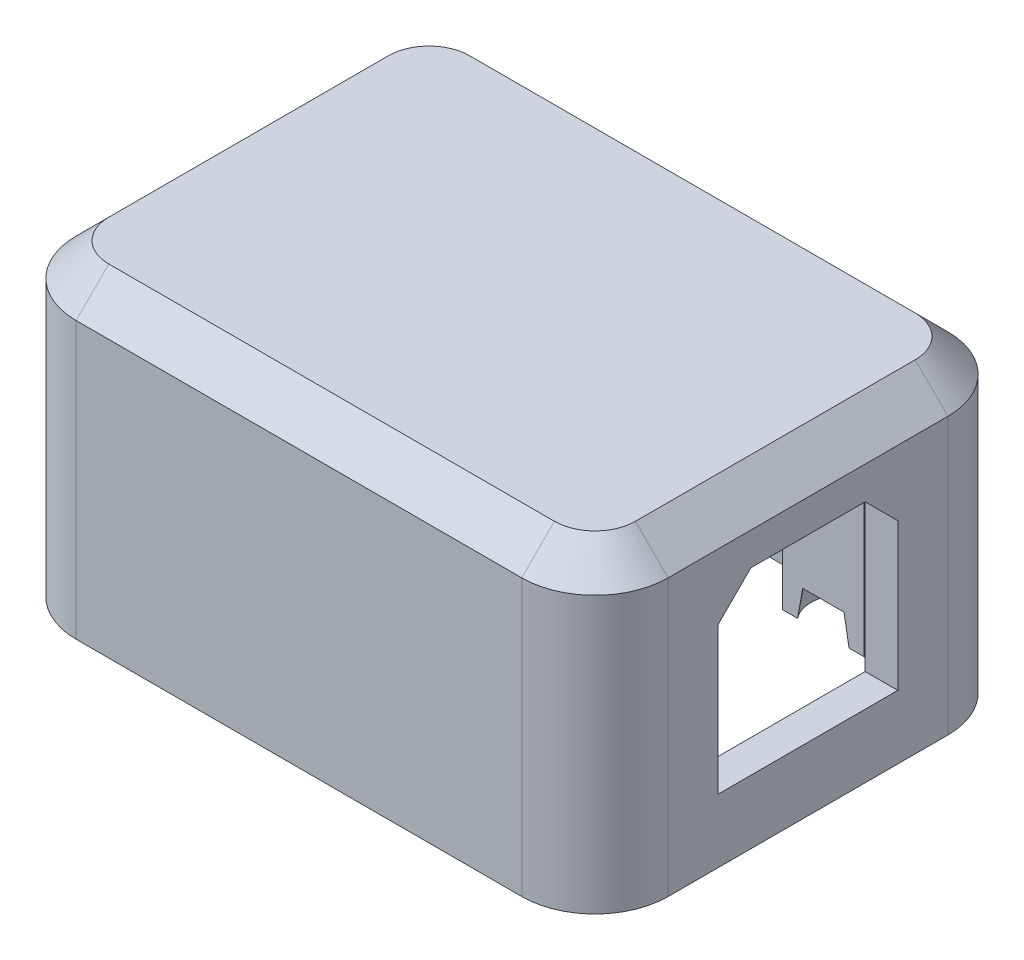
from build123d import *

# Parameters (mm, degrees)
MAIN_EXTRUSION_DEPTH             = 14
TAPERED_BOTTOM_DEPTH             = 2
TAPERED_BOTTOM_DRAFT             = -45
SKETCH4_R                        = 2.795
SKETCH4_W                        = 8
SKETCH4_H                        = 3.045
PCB_SUPPORT_DEPTH                = 13.75
SKETCH5_R                        = 2.045
GUIDE_PIN_CUTOUT_DEPTH           = 2
GUIDE_PIN_CUTOUT_DRAFT           = 7.5
GUIDE_PIN_CUTOUT_PROFILE_2_DEPTH = 2
GUIDE_PIN_CUTOUT_PROFILE_2_DRAFT = 7.5
SKETCH12_W                       = 4.994797294
SKETCH12_H                       = 14
CUT_EXTRUDE6_DEPTH               = 13.75
SKETCH11_W                       = 7
SKETCH11_H                       = 7
BOSS_EXTRUDE1_DEPTH              = 2
CUT_EXTRUDE2_REACH               = 48.243
SKETCH8_R                        = 6.5
CUT_EXTRUDE4_DEPTH               = 0.5
CUT_EXTRUDE5_REACH               = 48.243
CHAMFER1_SIZE                    = 0.5


with BuildPart() as part:
    # Sketch2 → main-extrusion (new body)
    with BuildSketch(Plane(origin=(0, 0, 0), x_dir=(1, 0, 0), z_dir=(0, 1, 0))):
        with BuildLine():
            Line((-2.25, 19.36), (-2.25, 2.23))
            ThreePointArc((-2.25, 2.23), (-0.93783838, -0.93783838), (2.23, -2.25))
            Line((2.23, -2.25), (29.52, -2.25))
            ThreePointArc((29.52, -2.25), (32.68783838, -0.93783838), (34, 2.23))
            Line((34, 2.23), (34, 19.36))
            ThreePointArc((34, 19.36), (32.68783838, 22.52783838), (29.52, 23.84))
            Line((29.52, 23.84), (2.23, 23.84))
            ThreePointArc((2.23, 23.84), (-0.93783838, 22.52783838), (-2.25, 19.36))
        make_face()
        with BuildLine():
            Line((-0.25, 19.36), (-0.25, 2.23))
            ThreePointArc((-0.25, 2.23), (0.476375183, 0.476375183), (2.23, -0.25))
            Line((2.23, -0.25), (29.52, -0.25))
            ThreePointArc((29.52, -0.25), (31.273624817, 0.476375183), (32, 2.23))
            Line((32, 2.23), (32, 19.36))
            ThreePointArc((32, 19.36), (31.273624817, 21.113624817), (29.52, 21.84))
            Line((29.52, 21.84), (2.23, 21.84))
            ThreePointArc((2.23, 21.84), (0.476375183, 21.113624817), (-0.25, 19.36))
        make_face(mode=Mode.SUBTRACT)
    extrude(amount=MAIN_EXTRUSION_DEPTH)


with BuildPart() as tapered_bottom_tool:
    # Sketch3 → tapered-bottom (with draft: the straight prism first)
    with BuildSketch(Plane.XZ.offset(-14)):
        with BuildLine():
            ThreePointArc((-2.25, -19.36), (-0.93783838, -22.52783838), (2.23, -23.84))
            Line((2.23, -23.84), (29.52, -23.84))
            ThreePointArc((29.52, -23.84), (32.68783838, -22.52783838), (34, -19.36))
            Line((34, -19.36), (34, -2.23))
            ThreePointArc((34, -2.23), (32.68783838, 0.93783838), (29.52, 2.25))
            Line((29.52, 2.25), (2.23, 2.25))
            ThreePointArc((2.23, 2.25), (-0.93783838, 0.93783838), (-2.25, -2.23))
            Line((-2.25, -2.23), (-2.25, -19.36))
        make_face()
    extrude(amount=-TAPERED_BOTTOM_DEPTH)
    # tapered-bottom: the draft: its side faces are tilted about the plane it starts from
    tapered_bottom_sides = [tapered_bottom_tool.faces().sort_by_distance(p)[0] for p in [
        (-0.93783838, 15, -22.52783838),
        (15.875, 15, -23.84),
        (32.68783838, 15, -22.52783838),
        (34, 15, -10.795),
        (32.68783838, 15, 0.93783838),
        (15.875, 15, 2.25),
        (-0.93783838, 15, 0.93783838),
        (-2.25, 15, -10.795),
    ]]
    draft(tapered_bottom_sides, Plane.XZ.offset(-14), TAPERED_BOTTOM_DRAFT)


with BuildPart() as part_1:
    add(part.part)

    # tapered-bottom: add tapered_bottom_tool
    add(tapered_bottom_tool.part)

    # Sketch4 → PCB-support (add)
    with BuildSketch(Plane(origin=(0, 14, 0), x_dir=(1, 0, 0), z_dir=(0, 1, 0))):
        with Locations((27.94, 19.05)):
            Circle(SKETCH4_R)
        with Locations((27.94, 2.54)):
            Circle(SKETCH4_R)
        with Locations((13, 20.3175)):
            Rectangle(SKETCH4_W, SKETCH4_H)
        with Locations((13, 1.2725)):
            Rectangle(SKETCH4_W, SKETCH4_H)
    extrude(amount=-PCB_SUPPORT_DEPTH)


with BuildPart() as guide_pin_cutout_tool:
    # Sketch5 → guide-pin-cutout (with draft: the straight prism first)
    with BuildSketch(Plane(origin=(0, 0, 0), x_dir=(1, 0, 0), z_dir=(0, 1, 0))):
        with Locations((27.94, 19.05)):
            Circle(SKETCH5_R)
    extrude(amount=GUIDE_PIN_CUTOUT_DEPTH)
    # guide-pin-cutout: the draft: its side faces are tilted about the plane it starts from
    guide_pin_cutout_sides = [guide_pin_cutout_tool.faces().sort_by_distance(p)[0] for p in [
        (25.895, 1, -19.05),
    ]]
    draft(guide_pin_cutout_sides, Plane(origin=(0, 0, 0), x_dir=(1, 0, 0), z_dir=(0, 1, 0)), GUIDE_PIN_CUTOUT_DRAFT)


with BuildPart() as part_2:
    add(part_1.part)

    # guide-pin-cutout: cut by guide_pin_cutout_tool
    add(guide_pin_cutout_tool.part, mode=Mode.SUBTRACT)


with BuildPart() as guide_pin_cutout_profile_2_tool:
    # Sketch5 → guide-pin-cutout profile 2 (with draft: the straight prism first)
    with BuildSketch(Plane(origin=(0, 0, 0), x_dir=(1, 0, 0), z_dir=(0, 1, 0))):
        with Locations((27.94, 2.54)):
            Circle(SKETCH5_R)
    extrude(amount=GUIDE_PIN_CUTOUT_PROFILE_2_DEPTH)
    # guide-pin-cutout profile 2: the draft: its side faces are tilted about the plane it starts from
    guide_pin_cutout_profile_2_sides = [guide_pin_cutout_profile_2_tool.faces().sort_by_distance(p)[0] for p in [
        (25.895, 1, -2.54),
    ]]
    draft(guide_pin_cutout_profile_2_sides, Plane(origin=(0, 0, 0), x_dir=(1, 0, 0), z_dir=(0, 1, 0)), GUIDE_PIN_CUTOUT_PROFILE_2_DRAFT)


with BuildPart() as part_3:
    add(part_2.part)

    # guide-pin-cutout profile 2: cut by guide_pin_cutout_profile_2_tool
    add(guide_pin_cutout_profile_2_tool.part, mode=Mode.SUBTRACT)

    # Sketch12 → Cut-Extrude6 (cut)
    with BuildSketch(Plane.XZ.offset(-14)):
        with Locations((27.94, -10.795)):
            Rectangle(SKETCH12_W, SKETCH12_H)
    extrude(amount=CUT_EXTRUDE6_DEPTH, mode=Mode.SUBTRACT)

    # Sketch11 → Boss-Extrude1 (add)
    with BuildSketch(Plane.XZ.offset(-14)):
        with Locations((28.5, -10.795)):
            Rectangle(SKETCH11_W, SKETCH11_H)
    extrude(amount=BOSS_EXTRUDE1_DEPTH)

    # top-hook: sweep along a path in path
    with BuildLine(Plane.XZ) as top_hook_path:
        Line((2.23, 0.25), (29.52, 0.25))
        ThreePointArc((29.52, 0.25), (31.273624817, -0.476375183), (32, -2.23))
        Line((32, -2.23), (32, -19.36))
        ThreePointArc((32, -19.36), (31.273624817, -21.113624817), (29.52, -21.84))
        Line((29.52, -21.84), (2.23, -21.84))
        ThreePointArc((2.23, -21.84), (0.476375183, -21.113624817), (-0.25, -19.36))
        Line((-0.25, -19.36), (-0.25, -2.23))
        ThreePointArc((-0.25, -2.23), (0.476375183, -0.476375183), (2.23, 0.25))
    # hook → top-hook (sweep)
    with BuildSketch(Plane(origin=(29.52, 0, 0), x_dir=(0, 0, -1), z_dir=(1, 0, 0))):
        with BuildLine():
            Line((22.84, -2.9), (22.84, -1.3))
            ThreePointArc((22.84, -1.3), (23.19, -0.75), (22.84, -0.2))
            Line((22.84, -0.2), (22.84, 0))
            Line((22.84, 0), (23.84, 0))
            Line((23.84, 0), (23.84, -2.9))
            Line((23.84, -2.9), (22.84, -2.9))
        make_face()
    sweep(path=top_hook_path.line)

    # Sketch8 → Cut-Extrude2 (cut, up to next)
    with BuildSketch(Plane.ZY.offset(2.25), mode=Mode.PRIVATE) as cut_extrude2_sk1:
        with Locations((-10.795, 7)):
            Circle(SKETCH8_R)
    cut_extrude2_tool1 = extrude(cut_extrude2_sk1.sketch, amount=-CUT_EXTRUDE2_REACH, mode=Mode.PRIVATE) & part_3.part
    add(cut_extrude2_tool1.solids().sort_by_distance((-2.25, 7, -10.795))[0], mode=Mode.SUBTRACT)

    # Sketch9 → Cut-Extrude4 (cut)
    with BuildSketch(Plane.ZY.offset(2.25)):
        with BuildLine():
            Line((-18.295, 7), (-18.295, 12))
            ThreePointArc((-18.295, 12), (-17.709213562, 13.414213562), (-16.295, 14))
            Line((-16.295, 14), (-5.295, 14))
            ThreePointArc((-5.295, 14), (-3.880786438, 13.414213562), (-3.295, 12))
            Line((-3.295, 12), (-3.295, 7))
            ThreePointArc((-3.295, 7), (-10.795, -0.5), (-18.295, 7))
        make_face()
    extrude(amount=-CUT_EXTRUDE4_DEPTH, mode=Mode.SUBTRACT)

    # Sketch10 → Cut-Extrude5 (cut, up to next)
    with BuildSketch(Plane(origin=(34, 0, 0), x_dir=(0, 0, -1), z_dir=(1, 0, 0)), mode=Mode.PRIVATE) as cut_extrude5_sk1:
        Polygon((5.295, 1), (16.295, 1), (16.295, 10), (14.295, 12), (7.295, 12), (5.295, 10), align=None)
    cut_extrude5_tool1 = extrude(cut_extrude5_sk1.sketch, amount=-CUT_EXTRUDE5_REACH, mode=Mode.PRIVATE) & part_3.part
    add(cut_extrude5_tool1.solids().sort_by_distance((34, 6.334758, -10.795))[0], mode=Mode.SUBTRACT)

    # Chamfer1
    chamfer1_edges = [part_3.edges().sort_by_distance(p)[0] for p in [
        (15.875, -2.9, -22.84),
        (-0.230731599, -2.9, -21.820731599),
        (-1.25, -2.9, -10.795),
        (-0.230731599, -2.9, 0.230731599),
        (15.875, -2.9, 1.25),
        (31.980731599, -2.9, 0.230731599),
        (33, -2.9, -10.795),
        (31.980731599, -2.9, -21.820731599),
    ]]
    chamfer(chamfer1_edges, length=CHAMFER1_SIZE)


solid = part_3.part
